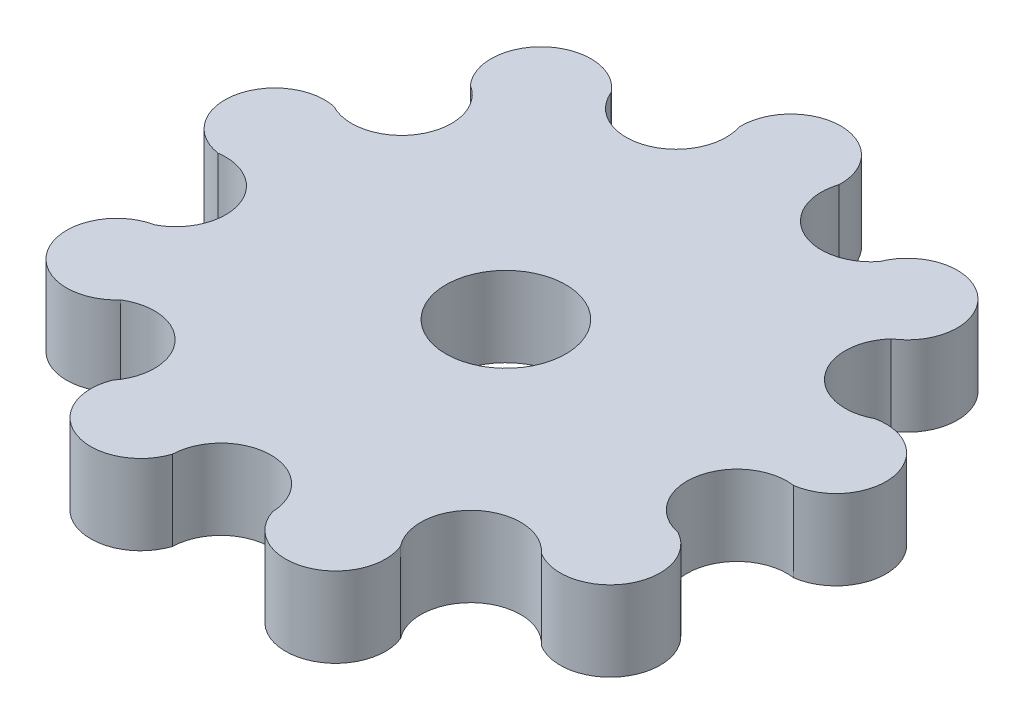
from build123d import *

# Parameters (mm, degrees)
BOSS_EXTRUDE2_DEPTH = 8
SKETCH2_R           = 6
CUT_EXTRUDE1_DEPTH  = 10


with BuildPart() as part:
    # Sketch1 → Boss-Extrude2 (new body)
    with BuildSketch(Plane(origin=(0, 0, 0), x_dir=(1, 0, 0), z_dir=(0, 1, 0))):
        with BuildLine():
            ThreePointArc((28.779527534, 0), (32.991059726, 5.817213952), (27.043909653, 9.843178132))
            ThreePointArc((27.043909653, 9.843178132), (20.752040899, 11.158464676), (20.954773741, 17.583142917))
            ThreePointArc((20.954773741, 17.583142917), (21.533384924, 25.662488844), (13.677257194, 23.689704368))
            ThreePointArc((13.677257194, 23.689704368), (7.385388439, 22.374417824), (4.99751251, 28.342301843))
            ThreePointArc((4.99751251, 28.342301843), (0, 33.5), (-4.99751251, 28.342301843))
            ThreePointArc((-4.99751251, 28.342301843), (-8.037473368, 22.082776588), (-14.389763767, 24.923801953))
            ThreePointArc((-14.389763767, 24.923801953), (-21.533384924, 25.662488844), (-22.046397143, 18.499123711))
            ThreePointArc((-22.046397143, 18.499123711), (-20.351596989, 11.75), (-27.043909653, 9.843178132))
            ThreePointArc((-27.043909653, 9.843178132), (-32.991059726, 5.817213952), (-28.779527534, 0))
            ThreePointArc((-28.779527534, 0), (-23.316959386, -3.387910912), (-25.704835315, -9.355794932))
            ThreePointArc((-25.704835315, -9.355794932), (-29.011851027, -16.75), (-20.954773741, -17.583142917))
            ThreePointArc((-20.954773741, -17.583142917), (-14.592496609, -18.499123711), (-14.389763767, -24.923801953))
            ThreePointArc((-14.389763767, -24.923801953), (-11.457674801, -31.479702796), (-4.99751251, -28.342301843))
            ThreePointArc((-4.99751251, -28.342301843), (0, -23.5), (4.99751251, -28.342301843))
            ThreePointArc((4.99751251, -28.342301843), (11.457674801, -31.479702796), (14.389763767, -24.923801953))
            ThreePointArc((14.389763767, -24.923801953), (15.105508828, -18.002044413), (22.046397143, -18.499123711))
            ThreePointArc((22.046397143, -18.499123711), (29.011851027, -16.75), (27.043909653, -9.843178132))
            ThreePointArc((27.043909653, -9.843178132), (23.142982196, -4.080732175), (28.779527534, 0))
        make_face()
    extrude(amount=BOSS_EXTRUDE2_DEPTH)

    # Sketch2 → Cut-Extrude1 (cut)
    with BuildSketch(Plane(origin=(0, 8, 0), x_dir=(1, 0, 0), z_dir=(0, 1, 0))):
        Circle(SKETCH2_R)
    extrude(amount=-CUT_EXTRUDE1_DEPTH, mode=Mode.SUBTRACT)


solid = part.part
